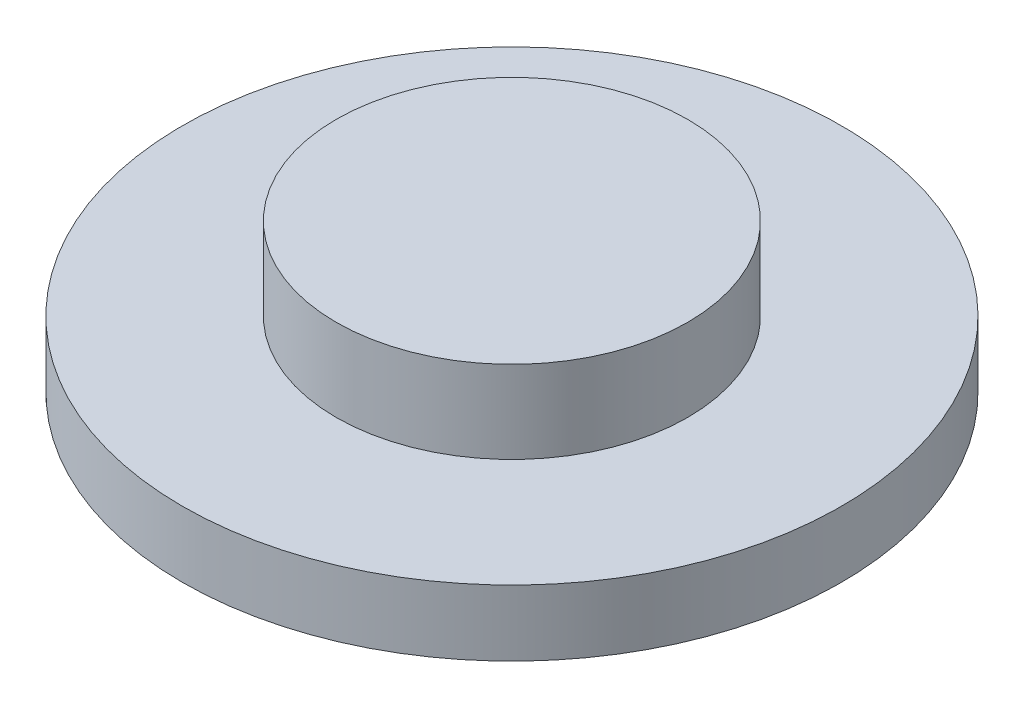
from build123d import *

# Parameters (mm, degrees)
SKETCH_1_R      = 15
EXTRUDE_1_DEPTH = 3
SKETCH_2_R      = 8
EXTRUDE_2_DEPTH = 3.75


with BuildPart() as part:
    # 草图1 → 凸台-拉伸1 (new body)
    with BuildSketch(Plane(origin=(0, 0, 0), x_dir=(1, 0, 0), z_dir=(0, 1, 0))):
        Circle(SKETCH_1_R)
    extrude(amount=EXTRUDE_1_DEPTH)

    # 草图2 → 凸台-拉伸2 (add)
    with BuildSketch(Plane(origin=(0, 3, 0), x_dir=(1, 0, 0), z_dir=(0, 1, 0))):
        Circle(SKETCH_2_R)
    extrude(amount=EXTRUDE_2_DEPTH)


solid = part.part
